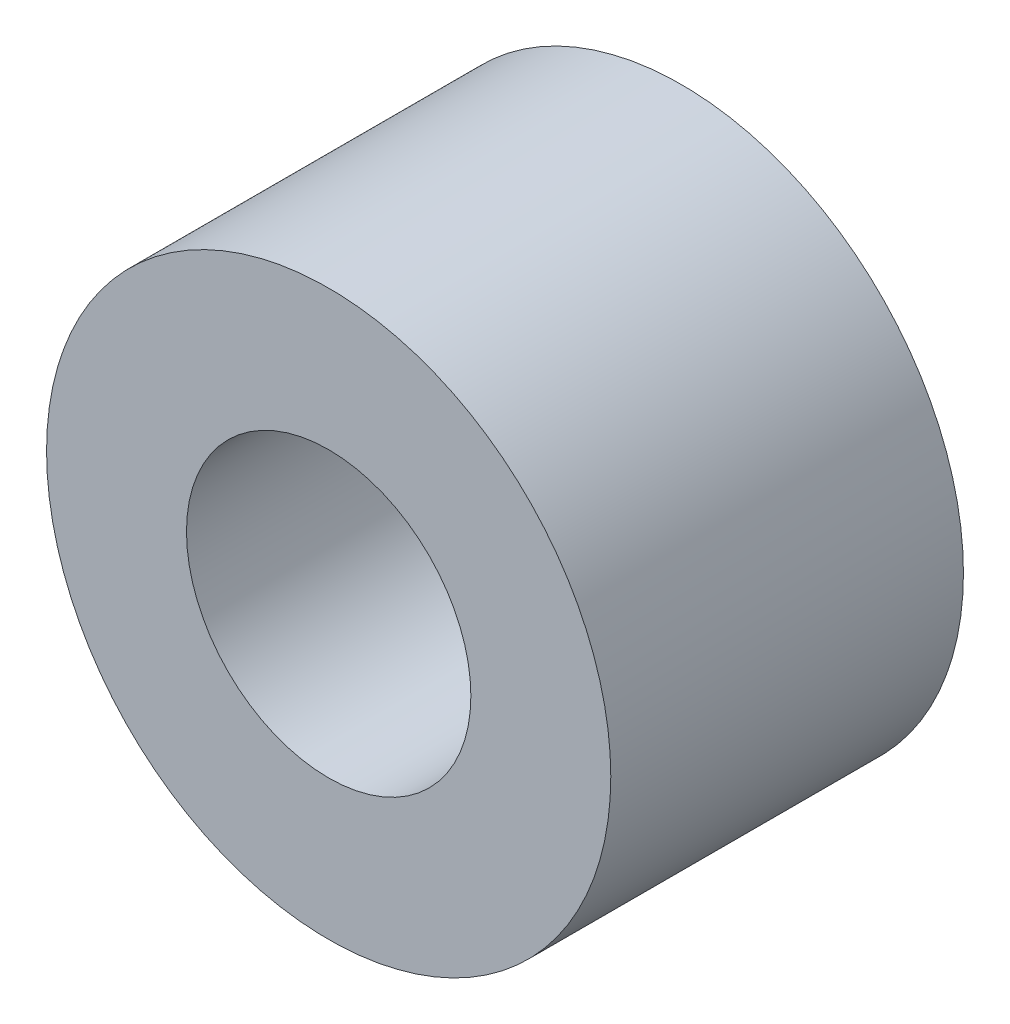
from build123d import *

# Parameters (mm, degrees)
SKETCH1_R      = 6.35
SKETCH1_R_2    = 3.2004
EXTRUDE1_DEPTH = 3.96875


with BuildPart() as part:
    # Sketch1 → Extrude1 (new body, symmetric)
    with BuildSketch(Plane.XY):
        Circle(SKETCH1_R)
        Circle(SKETCH1_R_2, mode=Mode.SUBTRACT)
    extrude(amount=EXTRUDE1_DEPTH, both=True)


solid = part.part
